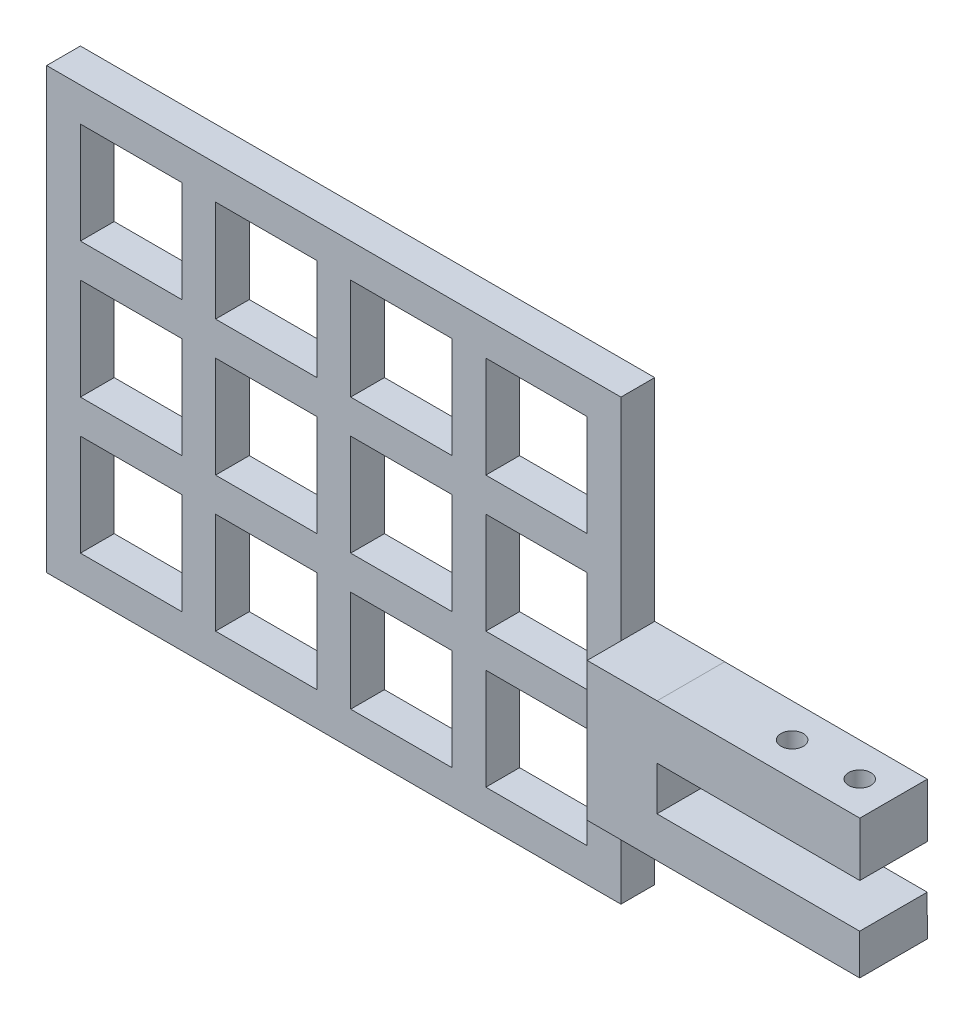
from build123d import *

# Parameters (mm, degrees)
EXTRUDE_1_DEPTH             = 10
HOLE_WIZARD_M4_1_D          = 3.3
HOLE_WIZARD_M4_1_DEPTH      = 7.999993258
CUT_EXTRUDE_1_DEPTH         = 5
SKETCH_6_W                  = 85
SKETCH_6_H                  = 65
EXTRUDE_2_DEPTH             = 5
SKETCH_7_W                  = 15
SKETCH_7_H                  = 15
CUT_EXTRUDE_2_DEPTH         = 5
PATTERN_LINEAR_1_COUNT      = 4
PATTERN_LINEAR_1_PITCH      = 20
PATTERN_LINEAR_1_COUNT_DIR2 = 3
PATTERN_LINEAR_1_PITCH_DIR2 = 20


with BuildPart() as part:
    # 草图1 → 凸台-拉伸1 (new body)
    with BuildSketch(Plane.XY):
        Polygon((0.020144186, -0.052366179), (0.016918395, 5.947632954), (-29.983056322, 5.986581065), (-29.962376808, 12.486559695), (0.03759791, 12.447611584), (0.03759791, 20.447611584), (-29.962376808, 20.486559695), (-40.315163894, 20.486559695), (-40.315163894, 0), align=None)
    extrude(amount=EXTRUDE_1_DEPTH)

    # M4 螺纹孔的螺纹孔钻头1
    with Locations(Plane(origin=(0.026546569, 20.447625932, 0), x_dir=(0.999999157, -0.00129827, 0), z_dir=(0.00129827, 0.999999157, 0))):
        with Locations((-15, -5), (-5, -5)):
            Hole(HOLE_WIZARD_M4_1_D / 2, depth=HOLE_WIZARD_M4_1_DEPTH)

    # 草图5 → 切除-拉伸1 (cut)
    with BuildSketch(Plane(origin=(0.016160415, 12.447639416, 0), x_dir=(0.999999157, -0.00129827, 0), z_dir=(-0.00129827, -0.999999157, 0))):
        with BuildLine():
            Line((-16.077032961, 2.2), (-13.922967039, 2.2))
            ThreePointArc((-13.922967039, 2.2), (-12, 5), (-13.922967039, 7.8))
            Line((-13.922967039, 7.8), (-16.077032961, 7.8))
            ThreePointArc((-16.077032961, 7.8), (-18, 5), (-16.077032961, 2.2))
        make_face()
        with BuildLine():
            Line((-6.077032961, 2.2), (-3.922967039, 2.2))
            ThreePointArc((-3.922967039, 2.2), (-2, 5), (-3.922967039, 7.8))
            Line((-3.922967039, 7.8), (-6.077032961, 7.8))
            ThreePointArc((-6.077032961, 7.8), (-8, 5), (-6.077032961, 2.2))
        make_face()
    extrude(amount=-CUT_EXTRUDE_1_DEPTH, mode=Mode.SUBTRACT)

    # 草图6 → 凸台-拉伸2 (add)
    with BuildSketch(Plane.XY):
        with Locations((-82.815163894, 19.23657038)):
            Rectangle(SKETCH_6_W, SKETCH_6_H)
    extrude(amount=EXTRUDE_2_DEPTH)

    # 草图7 → 切除-拉伸2 (cut)
    with BuildSketch(Plane.XY.offset(5)):
        with Locations((-112.815163894, 39.23657038)):
            Rectangle(SKETCH_7_W, SKETCH_7_H)
    cut_extrude_2 = extrude(amount=-CUT_EXTRUDE_2_DEPTH, mode=Mode.SUBTRACT)

    # 阵列(线性)1: Cut-Extrude 2 4 × 3
    with Locations(*[(i * PATTERN_LINEAR_1_PITCH, -j * PATTERN_LINEAR_1_PITCH_DIR2, 0) for i in range(PATTERN_LINEAR_1_COUNT) for j in range(PATTERN_LINEAR_1_COUNT_DIR2) if (i, j) != (0, 0)]):
        add(cut_extrude_2, mode=Mode.SUBTRACT)


solid = part.part
